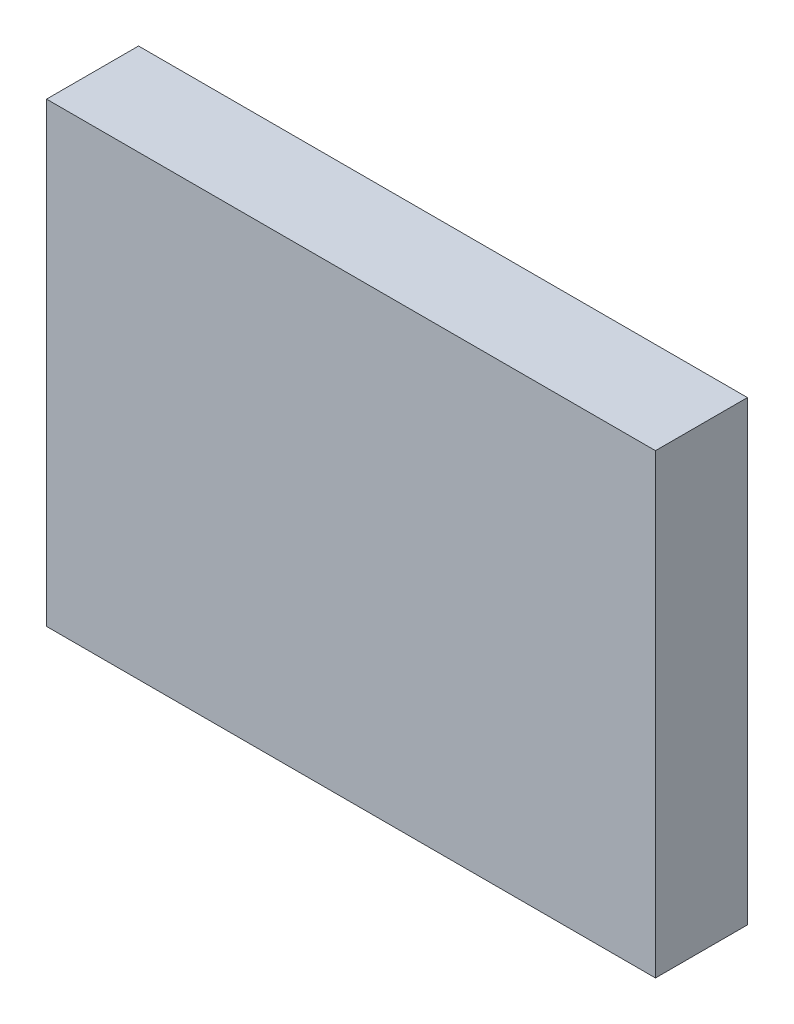
from build123d import *

# Parameters (mm, degrees)
SKETCH1_W           = 4.8
SKETCH1_H           = 3.6
BOSS_EXTRUDE1_DEPTH = 0.725


with BuildPart() as part:
    # Sketch1 → Boss-Extrude1 (new body)
    with BuildSketch(Plane.XY):
        Rectangle(SKETCH1_W, SKETCH1_H)
    extrude(amount=BOSS_EXTRUDE1_DEPTH)


solid = part.part
